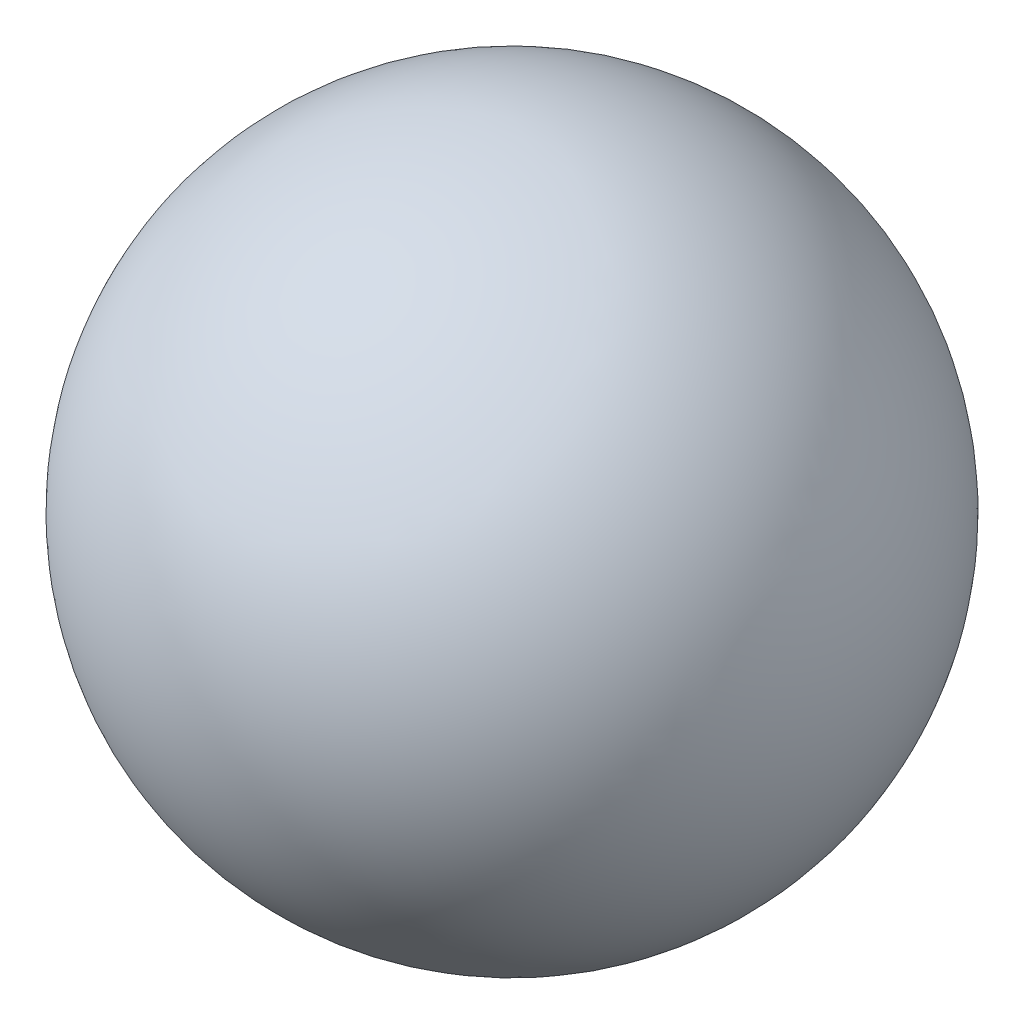
from build123d import *


with BuildPart() as part:
    # Sketch1 → Revolve1 (revolve)
    with BuildSketch(Plane(origin=(0, 0, 0), x_dir=(1, 0, 0), z_dir=(0, 1, 0))):
        with BuildLine():
            Line((-12.5, 0), (12.5, 0))
            ThreePointArc((12.5, 0), (0, -12.5), (-12.5, 0))
        make_face()
    revolve(axis=Axis((-12.5, 0, 0), (1, 0, 0)))


solid = part.part
